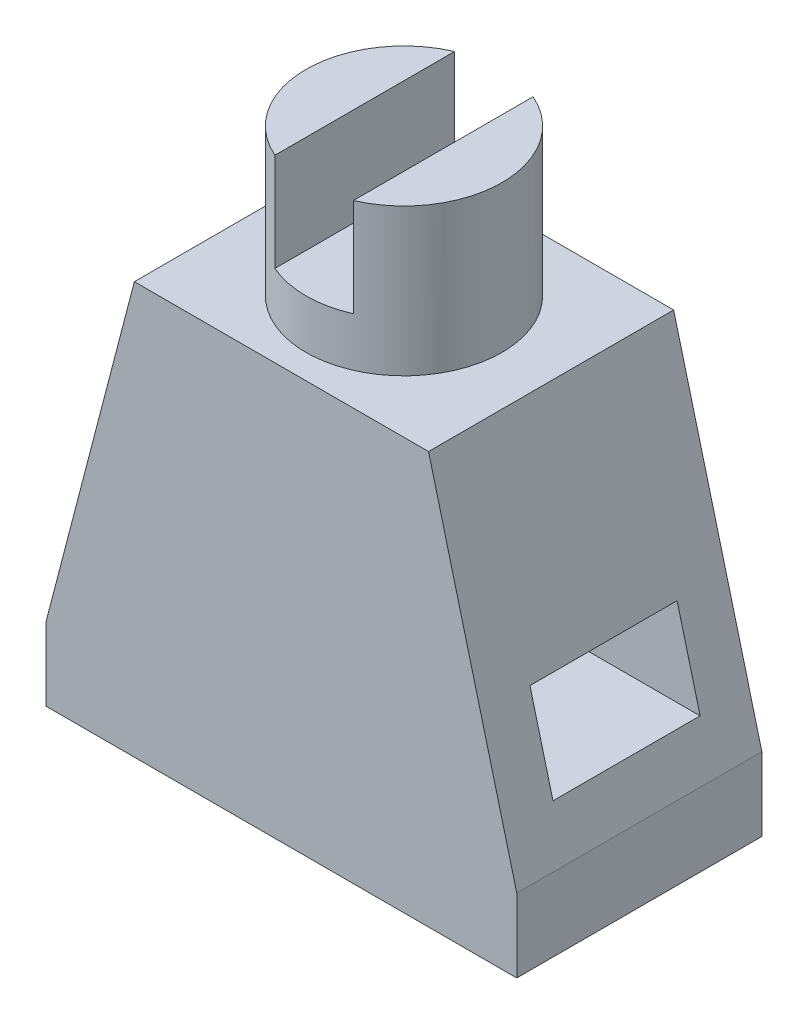
from build123d import *

# Parameters (mm, degrees)
SKETCH1_W           = 96
SKETCH1_H           = 50
BOSS_EXTRUDE1_DEPTH = 84
SKETCH5_W           = 30
SKETCH5_H           = 18
CUT_EXTRUDE2_DEPTH  = 102
CUT_EXTRUDE1_START  = -51
CUT_EXTRUDE1_DEPTH  = 52
SKETCH6_R           = 20
BOSS_EXTRUDE2_DEPTH = 30
CUT_EXTRUDE3_DEPTH  = 20


with BuildPart() as part:
    # Sketch1 → Boss-Extrude1 (new body)
    with BuildSketch(Plane(origin=(0, 0, 0), x_dir=(1, 0, 0), z_dir=(0, 1, 0))):
        with Locations((48, 25)):
            Rectangle(SKETCH1_W, SKETCH1_H)
    extrude(amount=BOSS_EXTRUDE1_DEPTH)

    # Sketch5 → Cut-Extrude2 (cut)
    with BuildSketch(Plane.ZY):
        with Locations((-25, 34)):
            Rectangle(SKETCH5_W, SKETCH5_H)
    extrude(amount=-CUT_EXTRUDE2_DEPTH, mode=Mode.SUBTRACT)

    # Sketch2 → Cut-Extrude1 (cut)
    with BuildSketch(Plane.XY.offset(CUT_EXTRUDE1_START)):
        Polygon((-62.209054952, -223.468043983), (0, 15), (18, 84), (80.209054952, 322.468043983), (-396.727033013, 446.886153886), (-539.145142917, -99.049934079), align=None)
    cut_extrude1 = extrude(amount=CUT_EXTRUDE1_DEPTH, mode=Mode.SUBTRACT)

    # Mirror1: Cut-Extrude1 across plane
    add(cut_extrude1.mirror(Plane.ZY.offset(-48)), mode=Mode.SUBTRACT)

    # Sketch6 → Boss-Extrude2 (add)
    with BuildSketch(Plane(origin=(0, 84, 0), x_dir=(1, 0, 0), z_dir=(0, 1, 0))):
        with Locations((48, 25)):
            Circle(SKETCH6_R)
    extrude(amount=BOSS_EXTRUDE2_DEPTH)

    # Sketch8 → Cut-Extrude3 (cut)
    with BuildSketch(Plane(origin=(0, 114, 0), x_dir=(1, 0, 0), z_dir=(0, 1, 0))):
        with BuildLine():
            Line((40, 6.66969722), (40, 43.33030278))
            ThreePointArc((40, 43.33030278), (48, 45), (56, 43.33030278))
            Line((56, 43.33030278), (56, 6.66969722))
            ThreePointArc((56, 6.66969722), (48, 5), (40, 6.66969722))
        make_face()
    extrude(amount=-CUT_EXTRUDE3_DEPTH, mode=Mode.SUBTRACT)


solid = part.part
